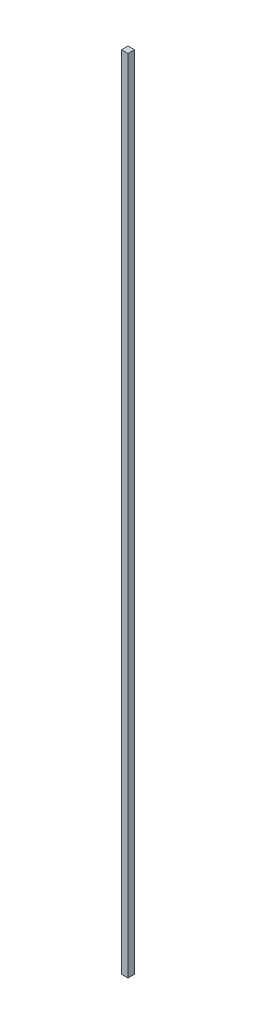
from build123d import *

# Parameters (mm, degrees)
SKETCH1_W           = 20
SKETCH1_H           = 20
BOSS_EXTRUDE1_DEPTH = 2465


with BuildPart() as part:
    # Sketch1 → Boss-Extrude1 (new body)
    with BuildSketch(Plane(origin=(0, 0, 0), x_dir=(1, 0, 0), z_dir=(0, 1, 0))):
        with Locations((10, -10)):
            Rectangle(SKETCH1_W, SKETCH1_H)
    extrude(amount=BOSS_EXTRUDE1_DEPTH)


solid = part.part
